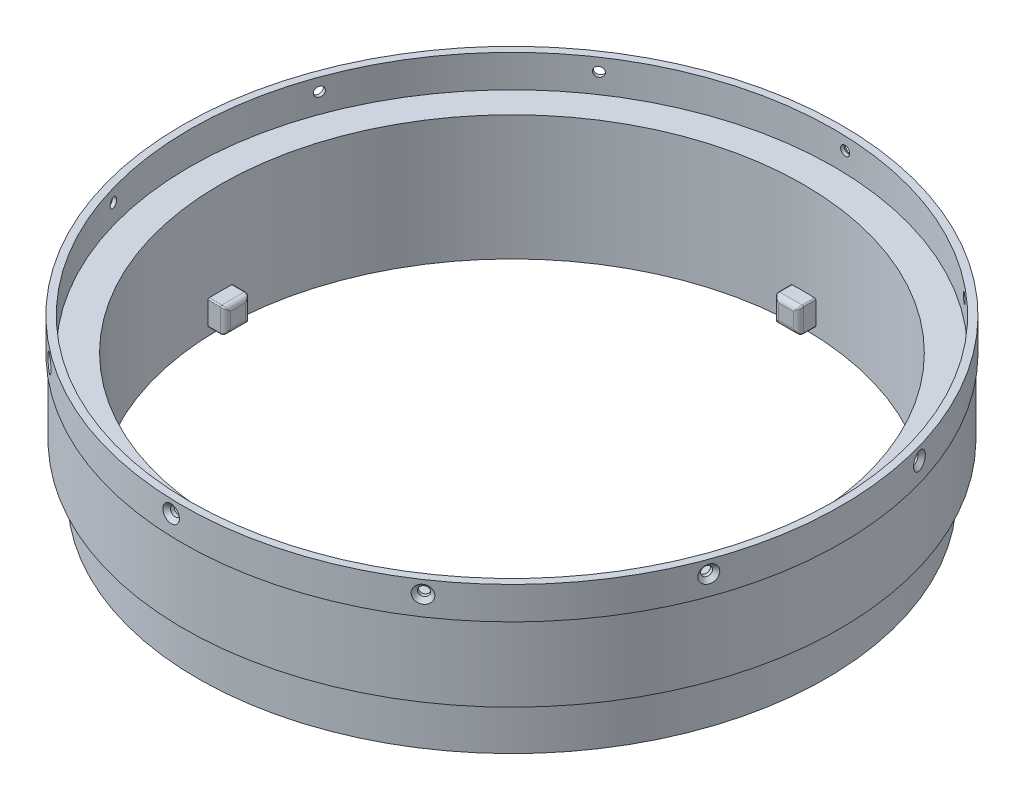
from build123d import *

# Parameters (mm, degrees)
CSK_FOR_M2_FLAT_HEAD_MACHINE_SCREW1_D           = 2.4
CSK_FOR_M2_FLAT_HEAD_MACHINE_SCREW1_CSINK_D     = 4.4
CSK_FOR_M2_FLAT_HEAD_MACHINE_SCREW1_CSINK_ANGLE = 90
CIRPATTERN1_COUNT                               = 10
SKETCH14_W                                      = 6.35
SKETCH14_H                                      = 6.35
BOSS_EXTRUDE1_DEPTH                             = 4.7625
FILLET1_R                                       = 1.27
FILLET2_R                                       = 0.3175
CIRPATTERN2_COUNT                               = 4
FILLET1_OF_CIRPATTERN2_R                        = 1.27
FILLET2_OF_CIRPATTERN2_R                        = 0.3175


with BuildPart() as part:
    # Sketch1 → Revolve1 (revolve)
    with BuildSketch(Plane.XY):
        Polygon((83.82, 42.324130435), (83.82, 34.069130435), (83.439, 34.069130435), (83.439, 15.019130435), (79.9338, 15.019130435), (79.9338, 2.319130435), (74.168, 2.319130435), (74.168, 34.069130435), (81.9531, 34.069130435), (81.9531, 42.324130435), align=None)
    revolve(axis=Axis((0, 49.143478261, 0), (0, -1, 0)))

    # CSK for M2 Flat Head Machine Screw1 (through all)
    with Locations(Plane(origin=(80.574007329, 39.078081592, -23.100254175), x_dir=(0.275593584, 0, 0.961274246), z_dir=(0.961274246, 0, -0.275593584))):
        with Locations((0, 0)):
            csk_for_m2_flat_head_machine_screw1 = CounterSinkHole(CSK_FOR_M2_FLAT_HEAD_MACHINE_SCREW1_D / 2, CSK_FOR_M2_FLAT_HEAD_MACHINE_SCREW1_CSINK_D / 2, counter_sink_angle=CSK_FOR_M2_FLAT_HEAD_MACHINE_SCREW1_CSINK_ANGLE)

    # CirPattern1: CSK for M2 Flat Head Machine Screw1 ×10 about axis
    cirpattern1_axis = Axis((0, 49.143478261, 0), (0, 1, 0))
    for i in range(1, CIRPATTERN1_COUNT):
        add(csk_for_m2_flat_head_machine_screw1.rotate(cirpattern1_axis, i * 360 / CIRPATTERN1_COUNT), mode=Mode.SUBTRACT)

    # Sketch14 → Boss-Extrude1 (add)
    with BuildSketch(Plane.XY.offset(74.422)):
        with Locations((0, 7.399130435)):
            Rectangle(SKETCH14_W, SKETCH14_H)
    boss_extrude1 = extrude(amount=-BOSS_EXTRUDE1_DEPTH)

    # Fillet1
    fillet1_edges = [part.edges().sort_by_distance(p)[0] for p in [
        (3.175, 7.399130435, 69.6595),
        (0, 4.224130435, 69.6595),
        (-3.175, 7.399130435, 69.6595),
        (0, 10.574130435, 69.6595),
    ]]
    fillet(fillet1_edges, radius=FILLET1_R)

    # Fillet2
    fillet2_edges = [part.edges().sort_by_distance(p)[0] for p in [
        (3.175, 4.224130435, 72.514755395),
        (3.175, 10.574130435, 72.514755395),
        (-3.175, 4.224130435, 72.514755395),
        (-3.175, 10.574130435, 72.514755395),
        (-2.725482112, 4.673648322, 69.960114059),
        (-2.725481956, 10.124612391, 69.960113926),
        (2.725481956, 4.673648479, 69.960113926),
        (2.725482112, 10.124612547, 69.960114059),
    ]]
    fillet(fillet2_edges, radius=FILLET2_R)

    # CirPattern2: Boss-Extrude1 ×4 about axis
    cirpattern2_axis = Axis((0, 49.143478261, 0), (0, 1, 0))
    for i in range(1, CIRPATTERN2_COUNT):
        add(boss_extrude1.rotate(cirpattern2_axis, i * 360 / CIRPATTERN2_COUNT))

    # Fillet1 of CirPattern2
    fillet1_of_cirpattern2_edges = [part.edges().sort_by_distance(p)[0] for p in [
        (69.6595, 7.399130435, -3.175),
        (69.6595, 4.224130435, 0),
        (69.6595, 7.399130435, 3.175),
        (69.6595, 10.574130435, 0),
        (-3.175, 7.399130435, -69.6595),
        (0, 4.224130435, -69.6595),
        (3.175, 7.399130435, -69.6595),
        (0, 10.574130435, -69.6595),
        (-69.6595, 7.399130435, 3.175),
        (-69.6595, 4.224130435, 0),
        (-69.6595, 7.399130435, -3.175),
        (-69.6595, 10.574130435, 0),
    ]]
    fillet(fillet1_of_cirpattern2_edges, radius=FILLET1_OF_CIRPATTERN2_R)

    # Fillet2 of CirPattern2
    fillet2_of_cirpattern2_edges = [part.edges().sort_by_distance(p)[0] for p in [
        (72.514755395, 4.224130435, -3.175),
        (72.514755395, 10.574130435, -3.175),
        (72.514755395, 4.224130435, 3.175),
        (72.514755395, 10.574130435, 3.175),
        (69.960114059, 4.673648322, 2.725482112),
        (69.960113926, 10.124612391, 2.725481956),
        (69.960113926, 4.673648479, -2.725481956),
        (69.960114059, 10.124612547, -2.725482112),
        (-3.175, 4.224130435, -72.514755395),
        (-3.175, 10.574130435, -72.514755395),
        (3.175, 4.224130435, -72.514755395),
        (3.175, 10.574130435, -72.514755395),
        (2.725482112, 4.673648322, -69.960114059),
        (2.725481956, 10.124612391, -69.960113926),
        (-2.725481956, 4.673648479, -69.960113926),
        (-2.725482112, 10.124612547, -69.960114059),
        (-72.514755395, 4.224130435, 3.175),
        (-72.514755395, 10.574130435, 3.175),
        (-72.514755395, 4.224130435, -3.175),
        (-72.514755395, 10.574130435, -3.175),
        (-69.960114059, 4.673648322, -2.725482112),
        (-69.960113926, 10.124612391, -2.725481956),
        (-69.960113926, 4.673648479, 2.725481956),
        (-69.960114059, 10.124612547, 2.725482112),
    ]]
    fillet(fillet2_of_cirpattern2_edges, radius=FILLET2_OF_CIRPATTERN2_R)


solid = part.part
